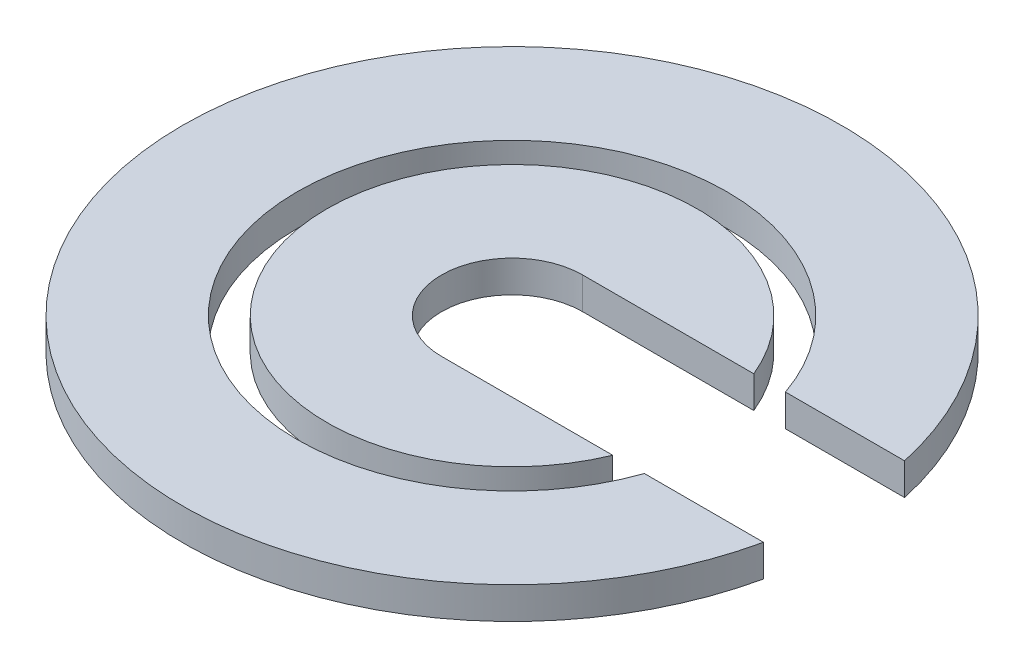
from build123d import *

# Parameters (mm, degrees)
BOSS_EXTRUDE1_DEPTH = 12.9
BOSS_EXTRUDE2_DEPTH = 12.9


with BuildPart() as part:
    # Sketch1 → Boss-Extrude1 (new body)
    with BuildSketch(Plane(origin=(0, 0, 0), x_dir=(1, 0, 0), z_dir=(0, 1, 0))):
        with BuildLine():
            Line((0, 28.575), (69.343127814, 28.575))
            ThreePointArc((69.343127814, 28.575), (-75, 0), (69.343127814, -28.575))
            Line((69.343127814, -28.575), (0, -28.575))
            ThreePointArc((0, -28.575), (-28.575, 0), (0, 28.575))
        make_face()
    extrude(amount=BOSS_EXTRUDE1_DEPTH)


with BuildPart() as body_2:
    # Sketch1_21 → Boss-Extrude2 (new body)
    with BuildSketch(Plane(origin=(0, 0, 0), x_dir=(1, 0, 0), z_dir=(0, 1, 0))):
        with BuildLine():
            Line((82.173411936, -28.575), (130.406718206, -28.575))
            ThreePointArc((130.406718206, -28.575), (-133.500722014, 0), (130.406718206, 28.575))
            Line((130.406718206, 28.575), (82.173411936, 28.575))
            ThreePointArc((82.173411936, 28.575), (-87.000001461, 0), (82.173411936, -28.575))
        make_face()
    extrude(amount=BOSS_EXTRUDE2_DEPTH)


solid = Compound([part.part, body_2.part])
